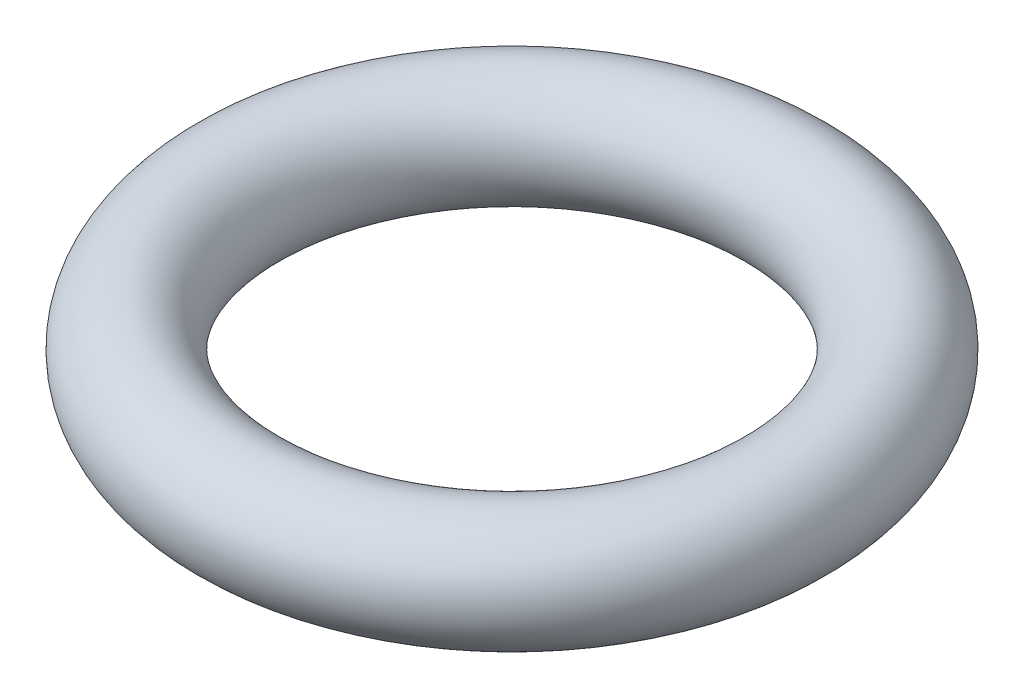
from build123d import *

# Parameters (mm, degrees)
SKETCH1_R = 2.5


with BuildPart() as part:
    # Sketch1 → Revolve1 (revolve)
    with BuildSketch(Plane.XY):
        with Locations((12, 0)):
            Circle(SKETCH1_R)
    revolve(axis=Axis((0, 20.495036722, 0), (0, -1, 0)))


solid = part.part
